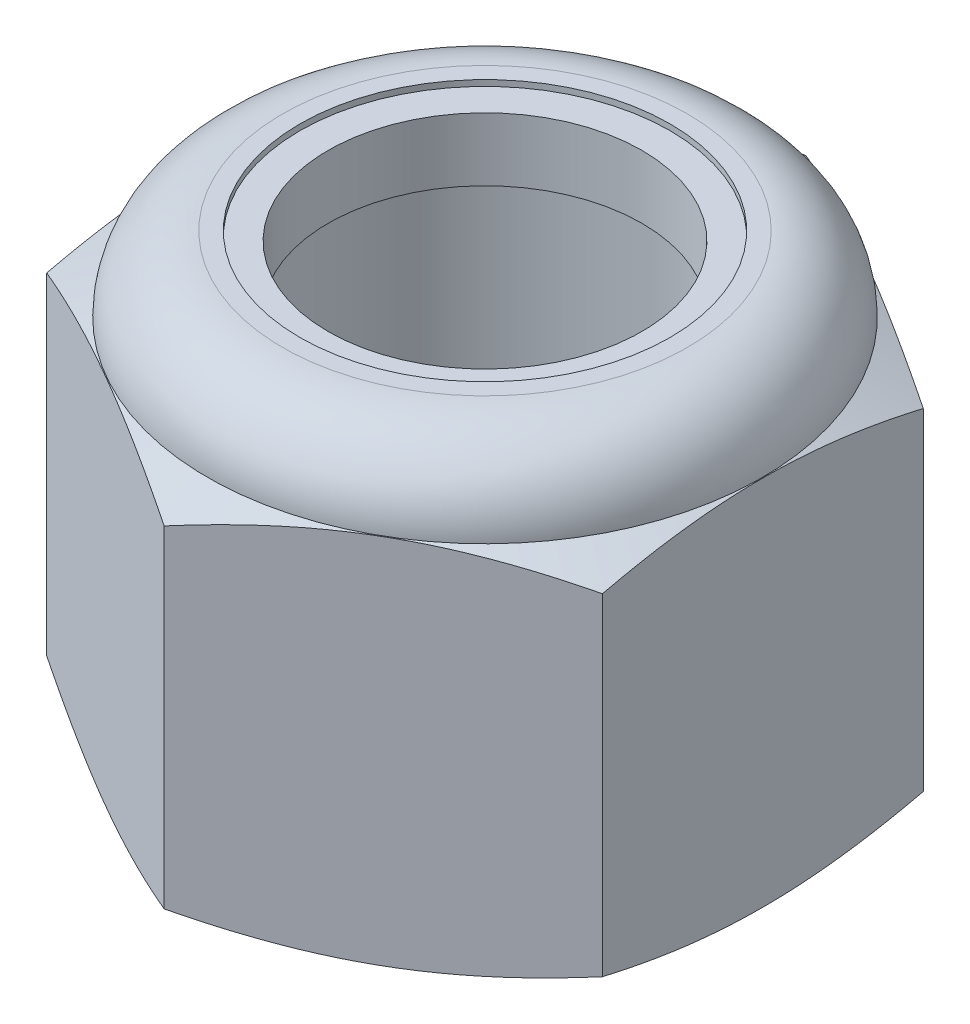
from build123d import *

# Parameters (mm, degrees)
BOSS_EXTRUDE1_DEPTH = 11.509375
SKETCH2_R           = 4.7625
CUT_EXTRUDE1_DEPTH  = 12.509375


with BuildPart() as part:
    # Sketch1 → Boss-Extrude1 (new body)
    with BuildSketch(Plane(origin=(0, 0, 0), x_dir=(1, 0, 0), z_dir=(0, 1, 0))):
        Polygon((0, 8.256224319), (-7.1501, 4.12811216), (-7.1501, -4.12811216), (0, -8.256224319), (7.1501, -4.12811216), (7.1501, 4.12811216), align=None)
    extrude(amount=BOSS_EXTRUDE1_DEPTH)

    # Sketch2 → Cut-Extrude1 (cut, through all)
    with BuildSketch(Plane(origin=(0, 11.509375, 0), x_dir=(1, 0, 0), z_dir=(0, 1, 0))):
        Circle(SKETCH2_R)
    extrude(amount=-CUT_EXTRUDE1_DEPTH, mode=Mode.SUBTRACT)

    # Sketch4 → Cut-Revolve1 (revolve, cut)
    with BuildSketch(Plane(origin=(0, 0, 0), x_dir=(0, 0, -1), z_dir=(1, 0, 0))):
        with BuildLine():
            Line((0, 0), (7.138624319, 0))
            Line((7.138624319, 0), (8.256224319, 0.521145439))
            Line((8.256224319, 0.521145439), (8.256224319, 9.057829561))
            Line((8.256224319, 9.057829561), (7.138624319, 9.578975))
            ThreePointArc((7.138624319, 9.578975), (6.57322325, 10.94397393), (5.208224319, 11.509375))
            Line((5.208224319, 11.509375), (5.208224319, 12.779375))
            Line((5.208224319, 12.779375), (9.526224319, 12.779375))
            Line((9.526224319, 12.779375), (9.526224319, -1.27))
            Line((9.526224319, -1.27), (0, -1.27))
            Line((0, -1.27), (0, 0))
        make_face()
    revolve(axis=Axis((0, 0, 0), (0, 1, 0)), mode=Mode.SUBTRACT)

    # Sketch5 → Cut-Revolve2 (revolve, cut)
    with BuildSketch(Plane(origin=(0, 0, 0), x_dir=(0, 0, -1), z_dir=(1, 0, 0))):
        with BuildLine():
            Line((6.986224319, 9.578975), (0, 9.578975))
            Line((0, 9.578975), (0, 12.118975))
            Line((0, 12.118975), (4.6228, 12.118975))
            Line((4.6228, 12.118975), (4.6228, 11.356975))
            Line((4.6228, 11.356975), (5.208224319, 11.356975))
            ThreePointArc((5.208224319, 11.356975), (6.465460176, 10.836210857), (6.986224319, 9.578975))
        make_face()
    revolve(axis=Axis((0, 9.578975, 0), (0, 1, 0)), mode=Mode.SUBTRACT)


with BuildPart() as body_2:
    # Sketch6 → Revolve1 (revolve)
    with BuildSketch(Plane(origin=(0, 0, 0), x_dir=(0, 0, -1), z_dir=(1, 0, 0))):
        with BuildLine():
            Line((4.0386, 9.655175), (4.0386, 11.280775))
            Line((4.0386, 11.280775), (5.208224319, 11.280775))
            ThreePointArc((5.208224319, 11.280775), (6.384329349, 10.808975081), (6.908317493, 9.655175))
            Line((6.908317493, 9.655175), (4.0386, 9.655175))
        make_face()
    revolve(axis=Axis((0, 0, 0), (0, 1, 0)))


solid = Compound([part.part, body_2.part])
